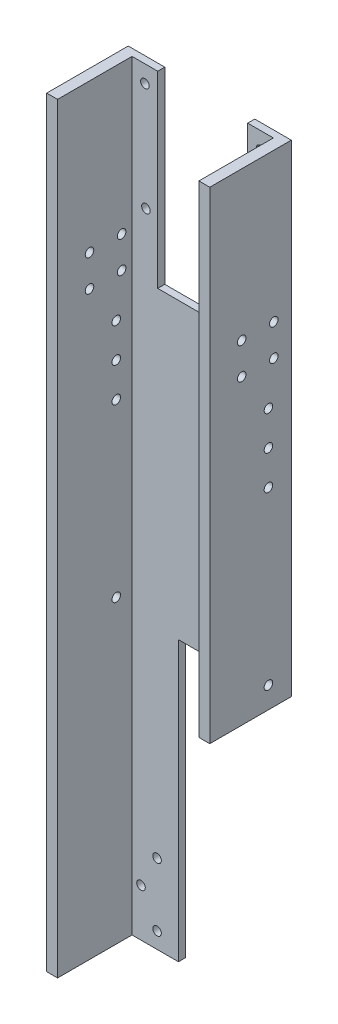
from build123d import *

# Parameters (mm, degrees)
BOSS_EXTRUDE1_DEPTH     = 177.8
SKETCH2_R               = 2
SKETCH2_W               = 21.020738686
SKETCH2_H               = 87.907641246
CUT_EXTRUDE1_DEPTH      = 4.302
SKETCH4_R               = 2
CUT_EXTRUDE2_DEPTH      = 4.302
SKETCH5_R               = 2
CUT_EXTRUDE3_DEPTH      = 77.2
CUT_EXTRUDE4_DEPTH      = 1
CUT_EXTRUDE4_DEPTH_BACK = 39.1


with BuildPart() as part:
    # Sketch1 → Boss-Extrude1 (new body, symmetric)
    with BuildSketch(Plane(origin=(0, 0, 0), x_dir=(1, 0, 0), z_dir=(0, 1, 0))):
        Polygon((-38.1, -19.05), (-33.02, -19.05), (-33.02, 15.748), (33.02, 15.748), (33.02, -19.05), (38.1, -19.05), (38.1, 19.05), (-38.1, 19.05), align=None)
    extrude(amount=BOSS_EXTRUDE1_DEPTH, both=True)

    # Sketch2 → Cut-Extrude1 (cut, through all)
    with BuildSketch(Plane.XY.offset(-15.748)):
        with Locations((-27.020369343, 169.8)):
            Circle(SKETCH2_R)
        with Locations((-26.52, 119.475689004)):
            Circle(SKETCH2_R)
        with Locations((-10.510369343, 133.846179377)):
            Rectangle(SKETCH2_W, SKETCH2_H)
    cut_extrude1 = extrude(amount=-CUT_EXTRUDE1_DEPTH, mode=Mode.SUBTRACT)

    # Mirror1: Cut-Extrude1 across plane
    add(cut_extrude1.mirror(Plane(origin=(0, 0, 0), x_dir=(0, 0, 1), z_dir=(1, 0, 0))), mode=Mode.SUBTRACT)

    # Sketch4 → Cut-Extrude2 (cut, through all)
    with BuildSketch(Plane.XY.offset(-15.748)):
        with Locations((-21.335, -170.3)):
            Circle(SKETCH4_R)
        with Locations((-28.835, -155.575)):
            Circle(SKETCH4_R)
        with Locations((-21.335, -140.85)):
            Circle(SKETCH4_R)
    extrude(amount=-CUT_EXTRUDE2_DEPTH, mode=Mode.SUBTRACT)

    # Sketch5 → Cut-Extrude3 (cut, through all)
    with BuildSketch(Plane.ZY.offset(38.1)):
        with Locations((-8.375, 58.5851)):
            Circle(SKETCH5_R)
        with Locations((-8.375, 74.5851)):
            Circle(SKETCH5_R)
        with Locations((-8.375, 42.5851)):
            Circle(SKETCH5_R)
        with Locations((-8.375, -37.4269)):
            Circle(SKETCH5_R)
        with Locations((-10.875, 93.638)):
            Circle(SKETCH5_R)
        with Locations((4.125, 93.638)):
            Circle(SKETCH5_R)
        with Locations((4.125, 108.363)):
            Circle(SKETCH5_R)
        with Locations((-10.875, 108.363)):
            Circle(SKETCH5_R)
    extrude(amount=-CUT_EXTRUDE3_DEPTH, mode=Mode.SUBTRACT)

    # Sketch6 → Cut-Extrude4 (cut, two sides)
    with BuildSketch(Plane.XY.offset(19.05)) as cut_extrude4_sk:
        Polygon((766.139495362, -47.4269), (38.1, -47.4269), (-11.335, -47.4269), (-11.335, -177.8), (-11.335, -905.839495362), (1067.889453991, -1883.30591685), (1845.363949353, -1024.893321488), align=None)
    extrude(amount=CUT_EXTRUDE4_DEPTH, mode=Mode.SUBTRACT)
    extrude(cut_extrude4_sk.sketch, amount=-CUT_EXTRUDE4_DEPTH_BACK, mode=Mode.SUBTRACT)


solid = part.part
